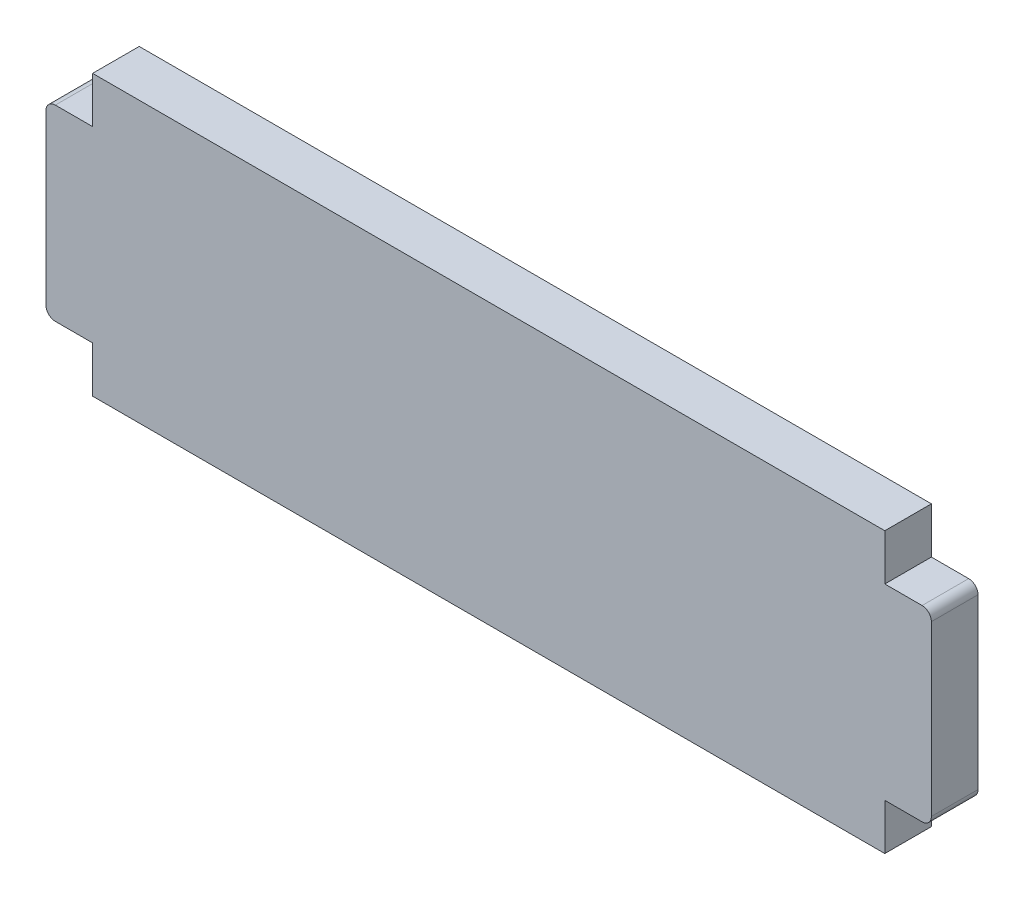
from build123d import *

# Parameters (mm, degrees)
BOSS_EXTRUDE1_DEPTH = 5
FILLET1_R           = 1


with BuildPart() as part:
    # Sketch1 → Boss-Extrude1 (new body)
    with BuildSketch(Plane.XY):
        Polygon((85, 25.05), (85, 30), (0, 30), (0, 25.05), (-5, 25.05), (-5, 4.95), (0, 4.95), (0, 0), (85, 0), (85, 4.95), (90, 4.95), (90, 25.05), align=None)
    extrude(amount=BOSS_EXTRUDE1_DEPTH)

    # Fillet1
    fillet1_edges = [part.edges().sort_by_distance(p)[0] for p in [
        (-5, 4.95, 2.5),
        (-5, 25.05, 2.5),
        (90, 25.05, 2.5),
        (90, 4.95, 2.5),
    ]]
    fillet(fillet1_edges, radius=FILLET1_R)


solid = part.part
